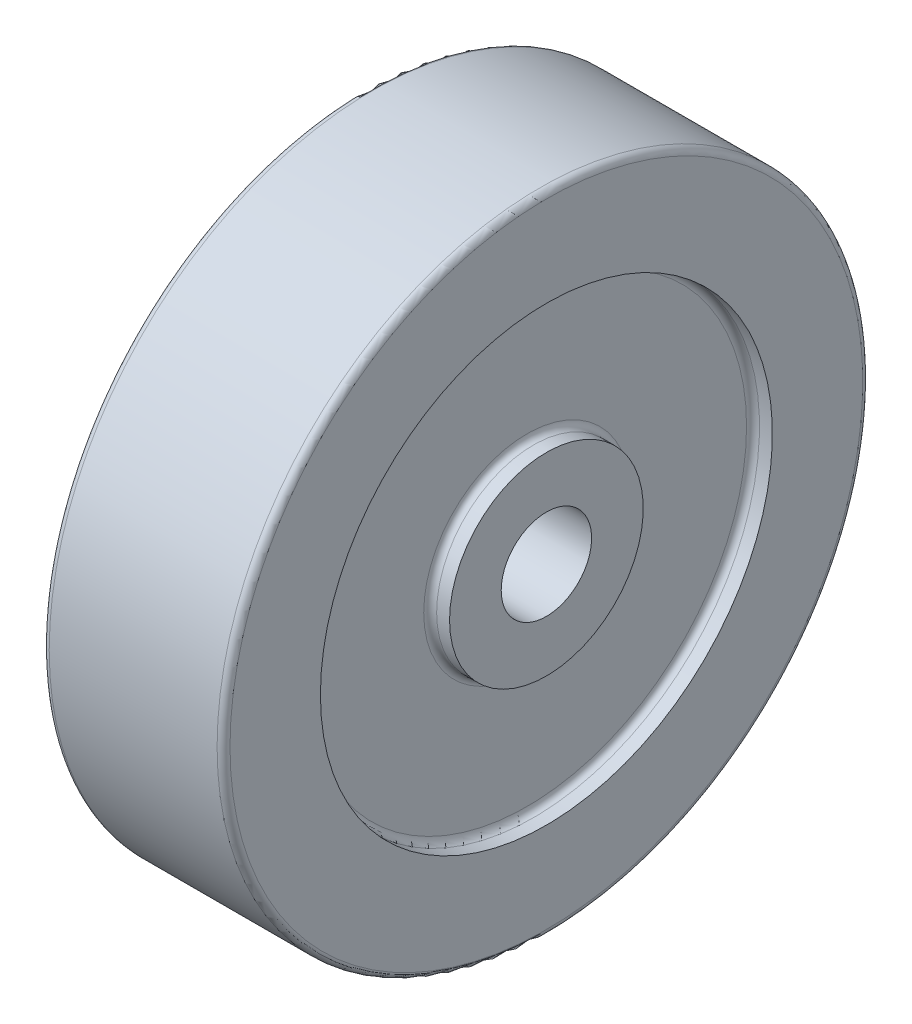
from build123d import *

# Parameters (mm, degrees)
FILLET1_R = 1


with BuildPart() as part:
    # Sketch1 → Revolve1 (revolve)
    with BuildSketch(Plane.XY):
        Polygon((14, 7), (14, 15), (11, 15), (11, 35), (14, 35), (14, 50), (-14, 50), (-14, 35), (-11, 35), (-11, 15), (-14, 15), (-14, 7), align=None)
    revolve(axis=Axis((0, 0, 0), (1, 0, 0)))

    # Fillet1
    fillet1_edges = [part.edges().sort_by_distance(p)[0] for p in [
        (-11, -15, 0),
        (-11, -35, 0),
        (-14, -50, 0),
        (14, -50, 0),
        (11, -35, 0),
        (11, -15, 0),
    ]]
    fillet(fillet1_edges, radius=FILLET1_R)


solid = part.part
